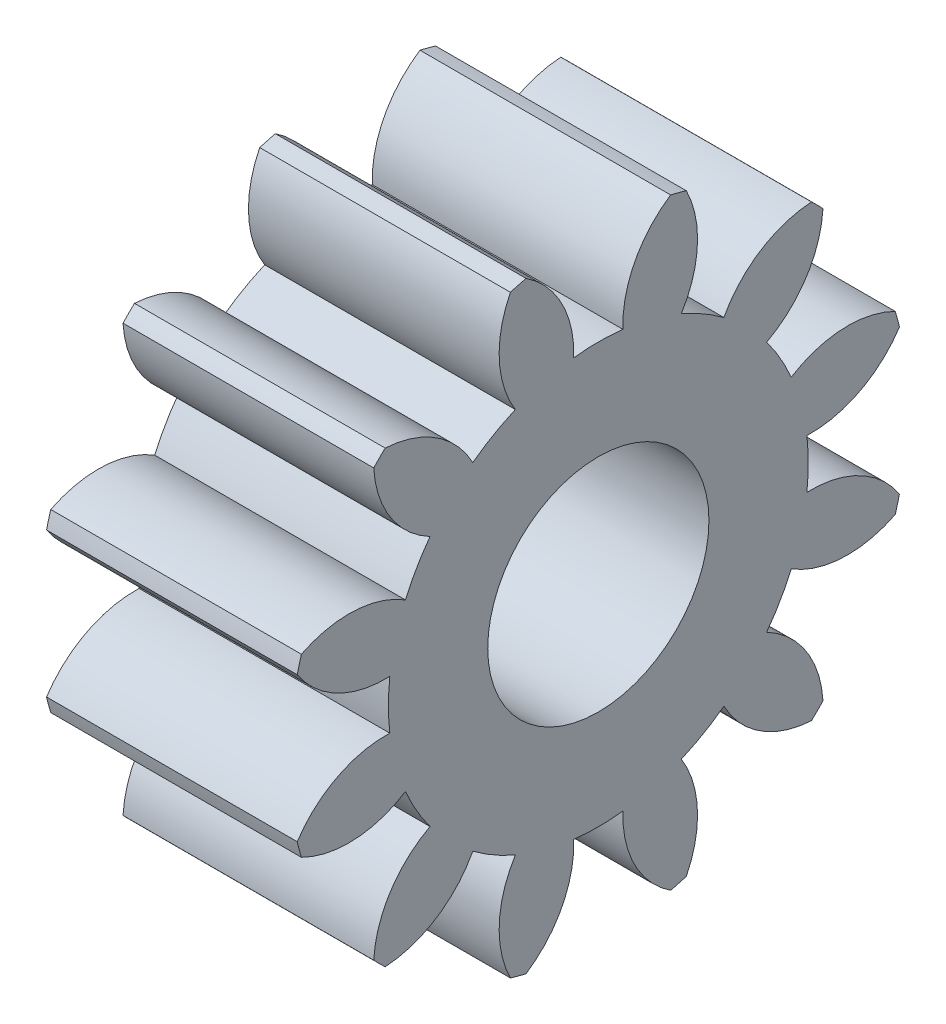
from build123d import *

# Parameters (mm, degrees)
BASPROSKE_W     = 1.7
BASPROSKE_H     = 2.1
TOOTHCUT_DEPTH  = 4.421987726
TEETHCUTS_COUNT = 12
TEETHCUTS_ANGLE = 330
BORSKE_R        = 0.75
BORE_DEPTH      = 50.0000508


with BuildPart() as part:
    # BasProSke → Base-Revolve (revolve)
    with BuildSketch(Plane(origin=(0, 0, 0), x_dir=(1, 0, 0), z_dir=(0, 1, 0)), mode=Mode.PRIVATE) as base_revolve_sk:
        with Locations((0.85, 1.05)):
            Rectangle(BASPROSKE_W, BASPROSKE_H)
    revolve(base_revolve_sk.sketch.rotate(Axis((-10, 0, 0), (1, 0, 0)), 180), axis=Axis((-10, 0, 0), (1, 0, 0)))

    # TooCutSke → ToothCut (cut, through all)
    with BuildSketch(Plane(origin=(0, 0, 0), x_dir=(0, 0, -1), z_dir=(1, 0, 0))):
        with BuildLine():
            ThreePointArc((0.16674814, 1.41420333), (0, 1.424), (-0.16674814, 1.41420333))
            ThreePointArc((-0.16674814, 1.41420333), (-0.254548019, 1.786124318), (-0.520302512, 2.060730564))
            ThreePointArc((-0.520302512, 2.060730564), (0, 2.1254), (0.520302512, 2.060730564))
            ThreePointArc((0.520302512, 2.060730564), (0.254548019, 1.786124318), (0.16674814, 1.41420333))
        make_face()
    toothcut = extrude(amount=TOOTHCUT_DEPTH, mode=Mode.SUBTRACT)

    # TeethCuts: ToothCut ×12 about axis
    teethcuts_axis = Axis((-10, 0, 0), (1, 0, 0))
    for i in range(1, TEETHCUTS_COUNT):
        add(toothcut.rotate(teethcuts_axis, i * TEETHCUTS_ANGLE / (TEETHCUTS_COUNT - 1)), mode=Mode.SUBTRACT)

    # BorSke → Bore (cut, symmetric)
    with BuildSketch(Plane(origin=(0, 0, 0), x_dir=(0, 0, -1), z_dir=(1, 0, 0))):
        with Locations(Location((0, 0, 0), (0, 0, 180))):
            Circle(BORSKE_R)
    extrude(amount=BORE_DEPTH, both=True, mode=Mode.SUBTRACT)


solid = part.part
